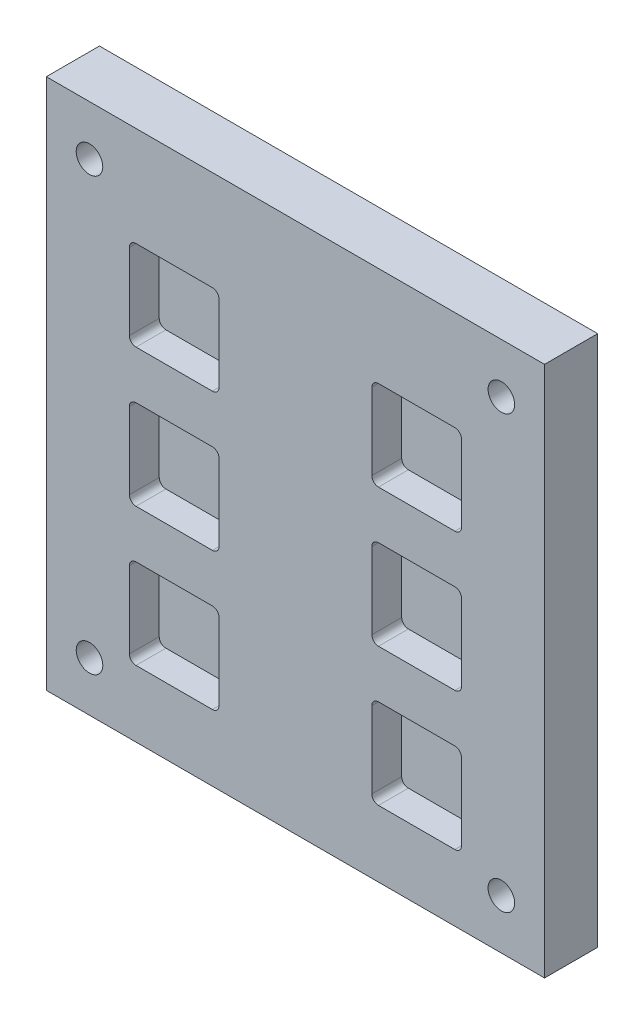
from build123d import *

# Parameters (mm, degrees)
SKETCH1_W           = 150
SKETCH1_H           = 160
BOSS_EXTRUDE1_DEPTH = 16
CUT_EXTRUDE1_DEPTH  = 9
SKETCH3_R           = 4
CUT_EXTRUDE2_DEPTH  = 17


with BuildPart() as part:
    # Sketch1 → Boss-Extrude1 (new body)
    with BuildSketch(Plane.XY):
        Rectangle(SKETCH1_W, SKETCH1_H)
    extrude(amount=BOSS_EXTRUDE1_DEPTH)

    # Sketch2 → Cut-Extrude1 (cut)
    with BuildSketch(Plane.XY.offset(16)):
        with BuildLine():
            Line((-48, 23), (-25, 23))
            ThreePointArc((-25, 23), (-23.585786438, 23.585786438), (-23, 25))
            Line((-23, 25), (-23, 48))
            ThreePointArc((-23, 48), (-23.585786438, 49.414213562), (-25, 50))
            Line((-25, 50), (-48, 50))
            ThreePointArc((-48, 50), (-49.414213562, 49.414213562), (-50, 48))
            Line((-50, 48), (-50, 25))
            ThreePointArc((-50, 25), (-49.414213562, 23.585786438), (-48, 23))
        make_face()
        with BuildLine():
            Line((23, 25), (23, 48))
            ThreePointArc((23, 48), (23.585786438, 49.414213562), (25, 50))
            Line((25, 50), (48, 50))
            ThreePointArc((48, 50), (49.414213562, 49.414213562), (50, 48))
            Line((50, 48), (50, 25))
            ThreePointArc((50, 25), (49.414213562, 23.585786438), (48, 23))
            Line((48, 23), (25, 23))
            ThreePointArc((25, 23), (23.585786438, 23.585786438), (23, 25))
        make_face()
        with BuildLine():
            Line((-48, -60), (-25, -60))
            ThreePointArc((-25, -60), (-23.585786438, -59.414213562), (-23, -58))
            Line((-23, -58), (-23, -35))
            ThreePointArc((-23, -35), (-23.585786438, -33.585786438), (-25, -33))
            Line((-25, -33), (-48, -33))
            ThreePointArc((-48, -33), (-49.414213562, -33.585786438), (-50, -35))
            Line((-50, -35), (-50, -58))
            ThreePointArc((-50, -58), (-49.414213562, -59.414213562), (-48, -60))
        make_face()
        with BuildLine():
            Line((23, -58), (23, -35))
            ThreePointArc((23, -35), (23.585786438, -33.585786438), (25, -33))
            Line((25, -33), (48, -33))
            ThreePointArc((48, -33), (49.414213562, -33.585786438), (50, -35))
            Line((50, -35), (50, -58))
            ThreePointArc((50, -58), (49.414213562, -59.414213562), (48, -60))
            Line((48, -60), (25, -60))
            ThreePointArc((25, -60), (23.585786438, -59.414213562), (23, -58))
        make_face()
        with BuildLine():
            Line((-25, -18.5), (-48, -18.5))
            ThreePointArc((-48, -18.5), (-49.414213562, -17.914213562), (-50, -16.5))
            Line((-50, -16.5), (-50, 6.5))
            ThreePointArc((-50, 6.5), (-49.414213562, 7.914213562), (-48, 8.5))
            Line((-48, 8.5), (-25, 8.5))
            ThreePointArc((-25, 8.5), (-23.585786438, 7.914213562), (-23, 6.5))
            Line((-23, 6.5), (-23, -16.5))
            ThreePointArc((-23, -16.5), (-23.585786438, -17.914213562), (-25, -18.5))
        make_face()
        with BuildLine():
            Line((50, -16.5), (50, 6.5))
            ThreePointArc((50, 6.5), (49.414213562, 7.914213562), (48, 8.5))
            Line((48, 8.5), (25, 8.5))
            ThreePointArc((25, 8.5), (23.585786438, 7.914213562), (23, 6.5))
            Line((23, 6.5), (23, -16.5))
            ThreePointArc((23, -16.5), (23.585786438, -17.914213562), (25, -18.5))
            Line((25, -18.5), (48, -18.5))
            ThreePointArc((48, -18.5), (49.414213562, -17.914213562), (50, -16.5))
        make_face()
    extrude(amount=-CUT_EXTRUDE1_DEPTH, mode=Mode.SUBTRACT)

    # Sketch3 → Cut-Extrude2 (cut, through all)
    with BuildSketch(Plane.XY.offset(16)):
        with Locations((-62, 65)):
            Circle(SKETCH3_R)
        with Locations((62, 65)):
            Circle(SKETCH3_R)
        with Locations((62, -65)):
            Circle(SKETCH3_R)
        with Locations((-62, -65)):
            Circle(SKETCH3_R)
    extrude(amount=-CUT_EXTRUDE2_DEPTH, mode=Mode.SUBTRACT)


solid = part.part
